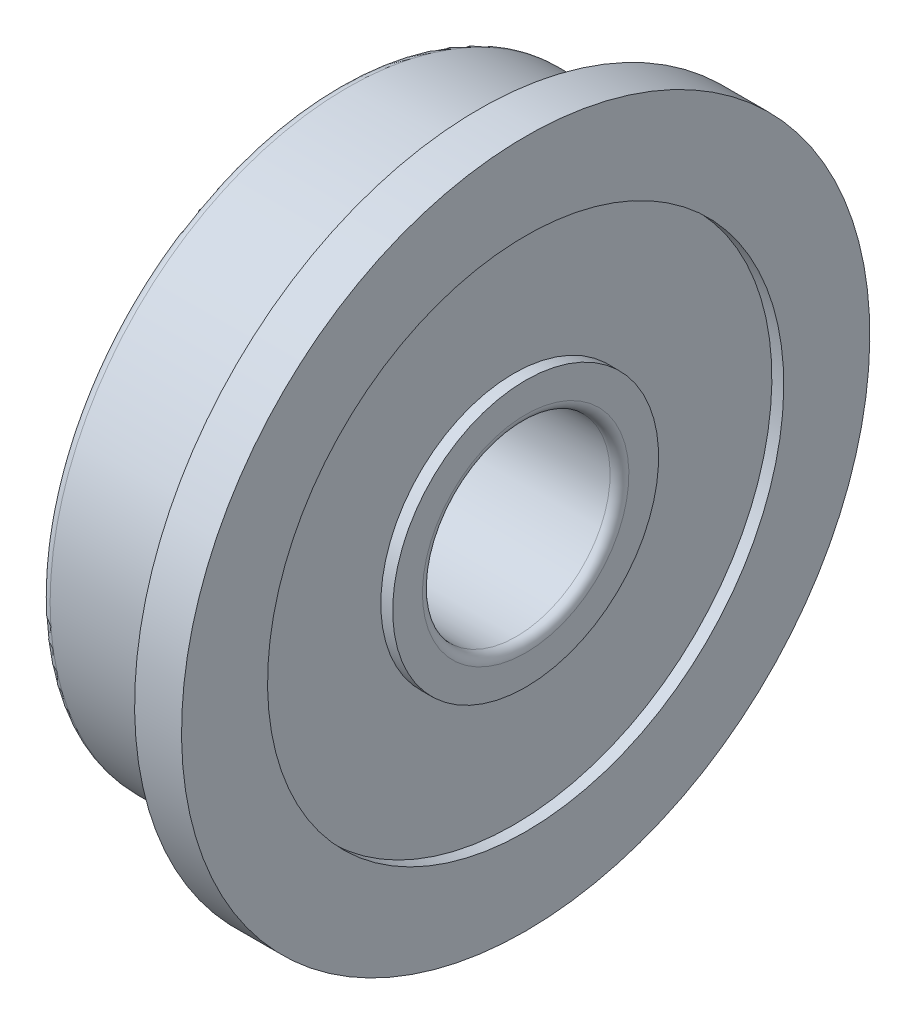
from build123d import *

# Parameters (mm, degrees)
FILLET1_R = 0.3


with BuildPart() as part:
    # Sketch1 → Revolve1 (revolve)
    with BuildSketch(Plane.XY):
        with BuildLine():
            Line((0, 9.7), (0, 11))
            Line((0, 11), (1.5, 11))
            Line((1.5, 11), (1.5, 8.25))
            Line((1.5, 8.25), (1.12, 8.25))
            Line((1.12, 8.25), (1.12, 4.25))
            Line((1.12, 4.25), (1.5, 4.25))
            Line((1.5, 4.25), (1.5, 3))
            Line((1.5, 3), (-4.5, 3))
            Line((-4.5, 3), (-4.5, 4.25))
            Line((-4.5, 4.25), (-4.12, 4.25))
            Line((-4.12, 4.25), (-4.12, 8.25))
            Line((-4.12, 8.25), (-4.5, 8.25))
            Line((-4.5, 8.25), (-4.5, 9.5))
            Line((-4.5, 9.5), (-0.2, 9.5))
            ThreePointArc((-0.2, 9.5), (0.141421356, 9.358578644), (0, 9.7))
        make_face()
    revolve(axis=Axis((-4.5, 0, 0), (1, 0, 0)))

    # Fillet1
    fillet1_edges = [part.edges().sort_by_distance(p)[0] for p in [
        (1.5, -3, 0),
        (-4.5, -3, 0),
        (-4.5, -9.5, 0),
    ]]
    fillet(fillet1_edges, radius=FILLET1_R)


solid = part.part
